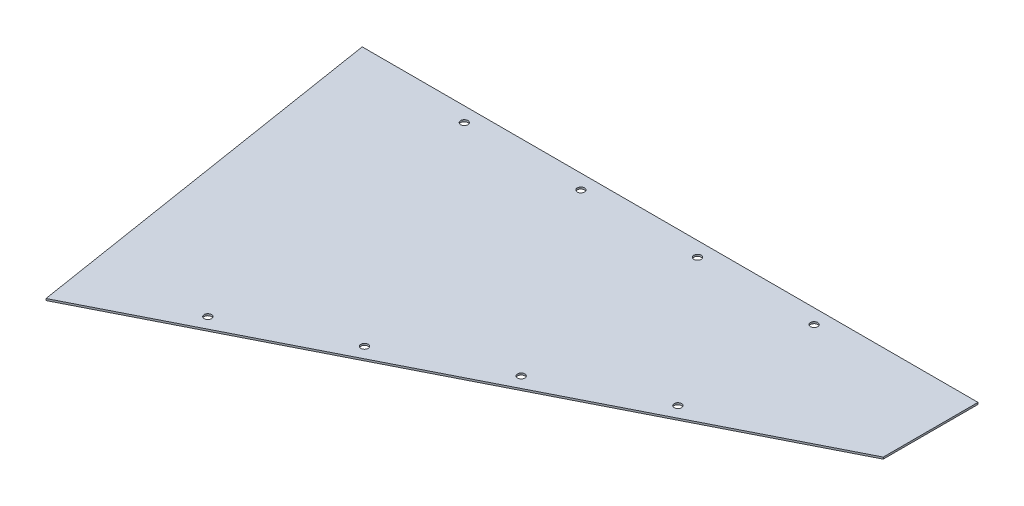
from build123d import *

# Parameters (mm, degrees)
BOSS_EXTRUDE1_DEPTH = 3.175
SKETCH3_R           = 6.35
CUT_EXTRUDE1_DEPTH  = 4.175


with BuildPart() as part:
    # Sketch1 → Boss-Extrude1 (new body)
    with BuildSketch(Plane(origin=(0, 0, 0), x_dir=(1, 0, 0), z_dir=(0, 1, 0))):
        Polygon((0, 0), (0, 165.1), (-1073.15, 165.1), (-968.887028118, -490.232750074), align=None)
    extrude(amount=BOSS_EXTRUDE1_DEPTH)

    # Sketch3 → Cut-Extrude1 (cut, through all)
    with BuildSketch(Plane(origin=(0, 3.175, 0), x_dir=(1, 0, 0), z_dir=(0, 1, 0))):
        with Locations((-869.783056686, 139.7)):
            Circle(SKETCH3_R)
        with Locations((-666.583056686, 139.7)):
            Circle(SKETCH3_R)
        with Locations((-463.383056686, 139.7)):
            Circle(SKETCH3_R)
        with Locations((-260.183056686, 139.7)):
            Circle(SKETCH3_R)
        with Locations((-800.504721955, -376.569229128)):
            Circle(SKETCH3_R)
        with Locations((-619.192529558, -284.829767126)):
            Circle(SKETCH3_R)
        with Locations((-437.880337162, -193.090305124)):
            Circle(SKETCH3_R)
        with Locations((-256.568144766, -101.350843122)):
            Circle(SKETCH3_R)
    extrude(amount=-CUT_EXTRUDE1_DEPTH, mode=Mode.SUBTRACT)


solid = part.part
